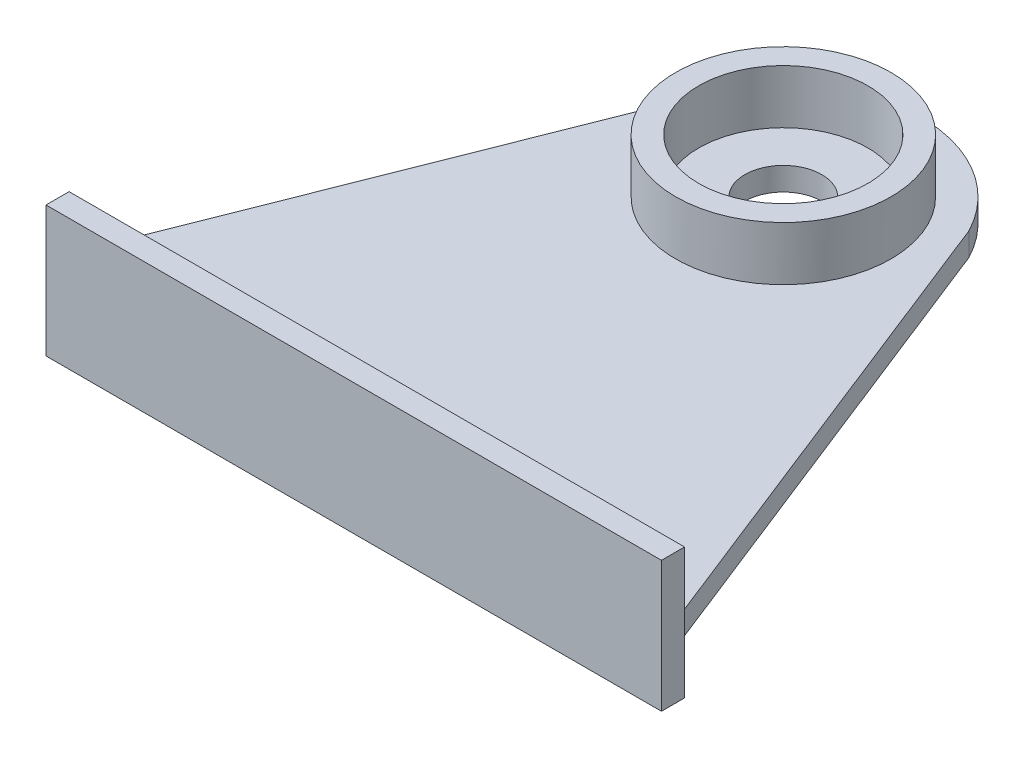
from build123d import *

# Parameters (mm, degrees)
BOSS_EXTRUDE1_DEPTH = 3
SKETCH2_R           = 14
SKETCH2_R_2         = 11
BOSS_EXTRUDE2_DEPTH = 7
SKETCH3_W           = 80
SKETCH3_H           = 17
BOSS_EXTRUDE3_DEPTH = 3
SKETCH5_R           = 5
CUT_EXTRUDE1_DEPTH  = 10


with BuildPart() as part:
    # Sketch1 → Boss-Extrude1 (new body)
    with BuildSketch(Plane(origin=(0, 0, 0), x_dir=(1, 0, 0), z_dir=(0, 1, 0))):
        with BuildLine():
            Line((-48.929144451, -17.835062273), (31.070855549, -17.835062273))
            Line((31.070855549, -17.835062273), (6.985518971, 43.196988966))
            ThreePointArc((6.985518971, 43.196988966), (-8.929144451, 52.904273338), (-24.843807874, 43.196988966))
            Line((-24.843807874, 43.196988966), (-48.929144451, -17.835062273))
        make_face()
    extrude(amount=BOSS_EXTRUDE1_DEPTH)

    # Sketch2 → Boss-Extrude2 (add)
    with BuildSketch(Plane(origin=(0, 3, 0), x_dir=(1, 0, 0), z_dir=(0, 1, 0))):
        with Locations((-8.929144451, 35.004937727)):
            Circle(SKETCH2_R)
        with Locations((-8.929144451, 35.004937727)):
            Circle(SKETCH2_R_2, mode=Mode.SUBTRACT)
    extrude(amount=BOSS_EXTRUDE2_DEPTH)

    # Sketch3 → Boss-Extrude3 (add)
    with BuildSketch(Plane.XY.offset(17.835062273)):
        with Locations((-8.929144451, 1.5)):
            Rectangle(SKETCH3_W, SKETCH3_H)
    extrude(amount=BOSS_EXTRUDE3_DEPTH)

    # Sketch5 → Cut-Extrude1 (cut)
    with BuildSketch(Plane(origin=(0, 3, 0), x_dir=(1, 0, 0), z_dir=(0, 1, 0))):
        with Locations((-8.929144451, 35.004937727)):
            Circle(SKETCH5_R)
    extrude(amount=-CUT_EXTRUDE1_DEPTH, mode=Mode.SUBTRACT)


solid = part.part
